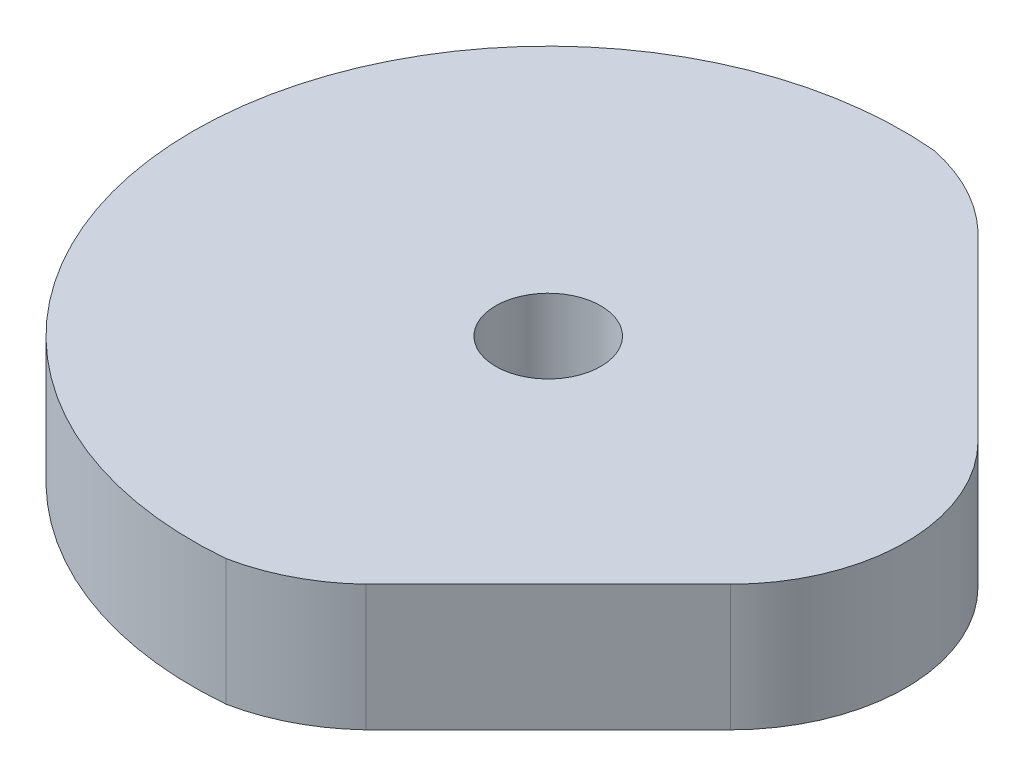
from build123d import *

# Parameters (mm, degrees)
SKETCH1_R           = 1.25
BOSS_EXTRUDE1_DEPTH = 3


with BuildPart() as part:
    # Sketch1 → Boss-Extrude1 (new body)
    with BuildSketch(Plane(origin=(0, 0, 0), x_dir=(1, 0, 0), z_dir=(0, 1, 0))):
        with BuildLine():
            ThreePointArc((0.75263713, 8.414705215), (-8.448297255, 0), (0.75263713, -8.414705215))
            ThreePointArc((0.75263713, -8.414705215), (1.926901999, -8.002285906), (2.941567446, -7.281562869))
            Line((2.941567446, -7.281562869), (7.281562869, -2.941567446))
            ThreePointArc((7.281562869, -2.941567446), (8.5, 0), (7.281562869, 2.941567446))
            Line((7.281562869, 2.941567446), (2.941567446, 7.281562869))
            ThreePointArc((2.941567446, 7.281562869), (1.926901999, 8.002285906), (0.75263713, 8.414705215))
        make_face()
        Circle(SKETCH1_R, mode=Mode.SUBTRACT)
    extrude(amount=BOSS_EXTRUDE1_DEPTH)


solid = part.part
